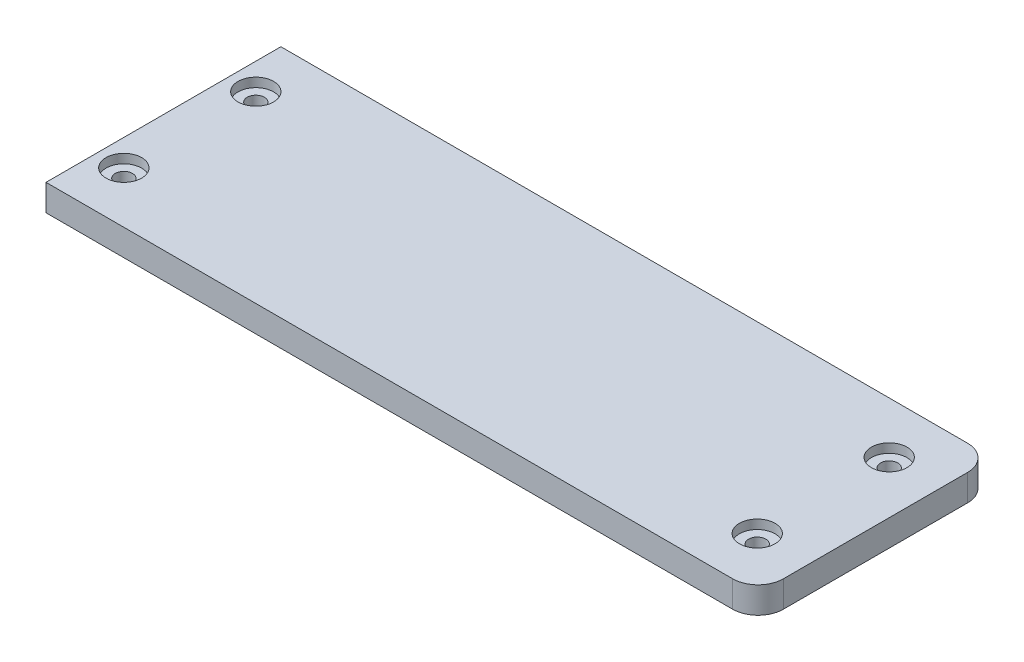
from build123d import *

# Parameters (mm, degrees)
SKETCH1_W                                           = 130
SKETCH1_H                                           = 44.5
BOSS_EXTRUDE1_DEPTH                                 = 5
CBORE_FOR_4_BINDING_HEAD_MACHINE_SCREW1_D           = 3.2639
CBORE_FOR_4_BINDING_HEAD_MACHINE_SCREW1_DEPTH       = 5
CBORE_FOR_4_BINDING_HEAD_MACHINE_SCREW1_CBORE_D     = 6.74624
CBORE_FOR_4_BINDING_HEAD_MACHINE_SCREW1_CBORE_DEPTH = 1.7272
BOSS_EXTRUDE2_DEPTH                                 = 5


with BuildPart() as part:
    # Sketch1 → Boss-Extrude1 (new body)
    with BuildSketch(Plane(origin=(0, 0, 0), x_dir=(1, 0, 0), z_dir=(0, 1, 0))):
        with Locations((-1.26999387, 6.518895388)):
            Rectangle(SKETCH1_W, SKETCH1_H)
    extrude(amount=BOSS_EXTRUDE1_DEPTH)

    # CBORE for #4 Binding Head Machine Screw1
    with Locations(Plane(origin=(0, 5, 0), x_dir=(1, 0, 0), z_dir=(0, 1, 0))):
        with Locations((-61.26999387, 19.018895388), (-61.26999387, -5.981104612), (58.73000613, -5.981104612), (58.73000613, 19.018895388)):
            CounterBoreHole(CBORE_FOR_4_BINDING_HEAD_MACHINE_SCREW1_D / 2, CBORE_FOR_4_BINDING_HEAD_MACHINE_SCREW1_CBORE_D / 2, CBORE_FOR_4_BINDING_HEAD_MACHINE_SCREW1_CBORE_DEPTH, depth=CBORE_FOR_4_BINDING_HEAD_MACHINE_SCREW1_DEPTH)

    # Sketch6 → Boss-Extrude2 (add)
    with BuildSketch(Plane(origin=(0, 5, 0), x_dir=(1, 0, 0), z_dir=(0, 1, 0))):
        with BuildLine():
            Line((63.73000613, 28.768895388), (63.83000613, 28.768895388))
            ThreePointArc((63.83000613, 28.768895388), (67.22411868, 27.363007938), (68.63000613, 23.968895388))
            Line((68.63000613, 23.968895388), (68.63000613, -10.931104612))
            ThreePointArc((68.63000613, -10.931104612), (67.22411868, -14.325217161), (63.83000613, -15.731104612))
            Line((63.83000613, -15.731104612), (63.73000613, -15.731104612))
            Line((63.73000613, -15.731104612), (63.73000613, 28.768895388))
        make_face()
    extrude(amount=-BOSS_EXTRUDE2_DEPTH)


solid = part.part
